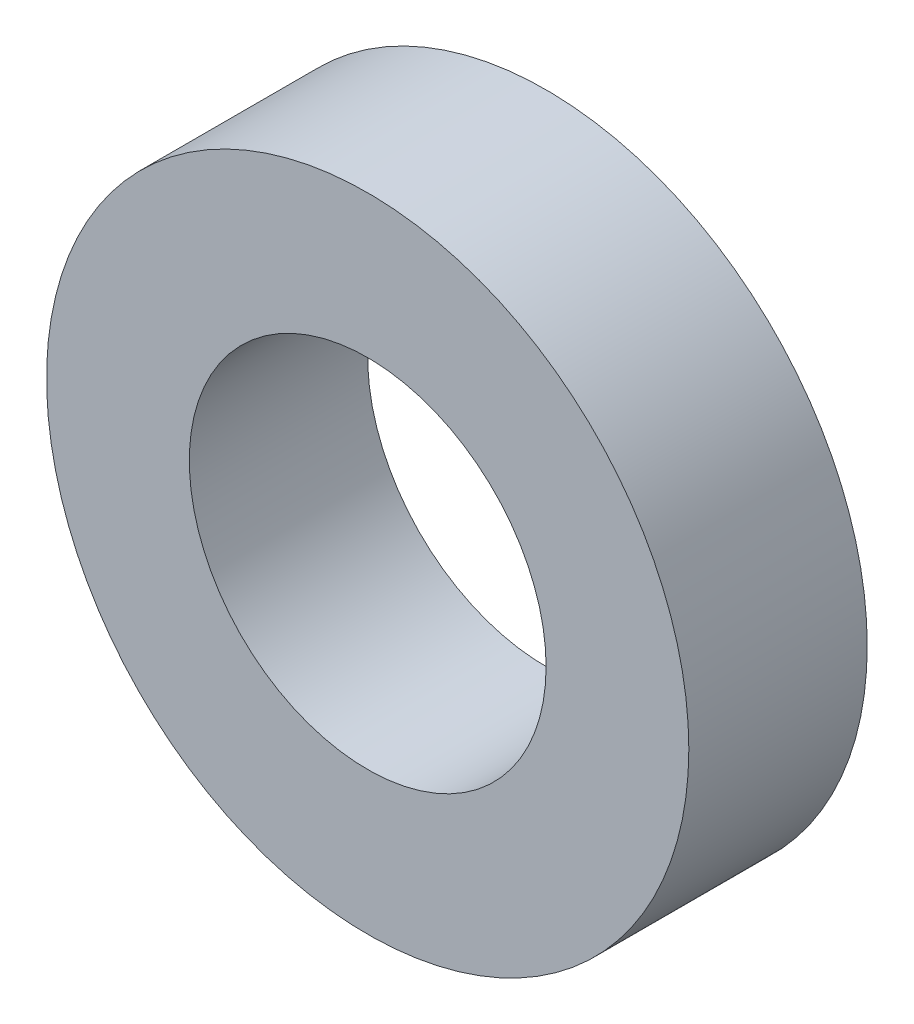
from build123d import *

# Parameters (mm, degrees)
SKIZZE1_R                       = 27
SKIZZE1_R_2                     = 15
AUFSATZ_LINEAR_AUSTRAGEN1_DEPTH = 15


with BuildPart() as part:
    # Skizze1 → Aufsatz-Linear austragen1 (new body)
    with BuildSketch(Plane.XY):
        Circle(SKIZZE1_R)
        Circle(SKIZZE1_R_2, mode=Mode.SUBTRACT)
    extrude(amount=AUFSATZ_LINEAR_AUSTRAGEN1_DEPTH)


solid = part.part
